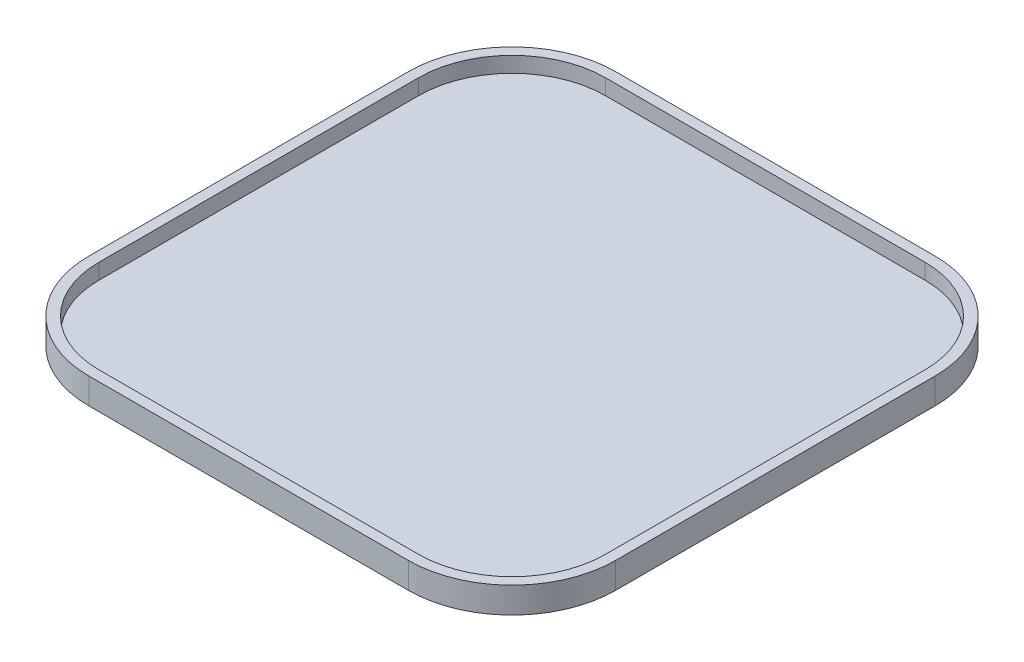
from build123d import *

# Parameters (mm, degrees)
BOSS_EXTRUDE1_DEPTH = 5
SHELL1_T            = -2


with BuildPart() as part:
    # Sketch1 → Boss-Extrude1 (new body)
    with BuildSketch(Plane(origin=(0, 0, 0), x_dir=(1, 0, 0), z_dir=(0, 1, 0))):
        with BuildLine():
            Line((30.8, -50.8), (-30.8, -50.8))
            ThreePointArc((-30.8, -50.8), (-44.942135624, -44.942135624), (-50.8, -30.8))
            Line((-50.8, -30.8), (-50.8, 30.8))
            ThreePointArc((-50.8, 30.8), (-44.942135624, 44.942135624), (-30.8, 50.8))
            Line((-30.8, 50.8), (30.8, 50.8))
            ThreePointArc((30.8, 50.8), (44.942135624, 44.942135624), (50.8, 30.8))
            Line((50.8, 30.8), (50.8, -30.8))
            ThreePointArc((50.8, -30.8), (44.942135624, -44.942135624), (30.8, -50.8))
        make_face()
    extrude(amount=BOSS_EXTRUDE1_DEPTH)

    # Shell1
    shell1_openings = [part.faces().sort_by_distance(p)[0] for p in [
        (0, 5, 0),
    ]]
    offset(amount=SHELL1_T, openings=shell1_openings, kind=Kind.INTERSECTION)


solid = part.part
